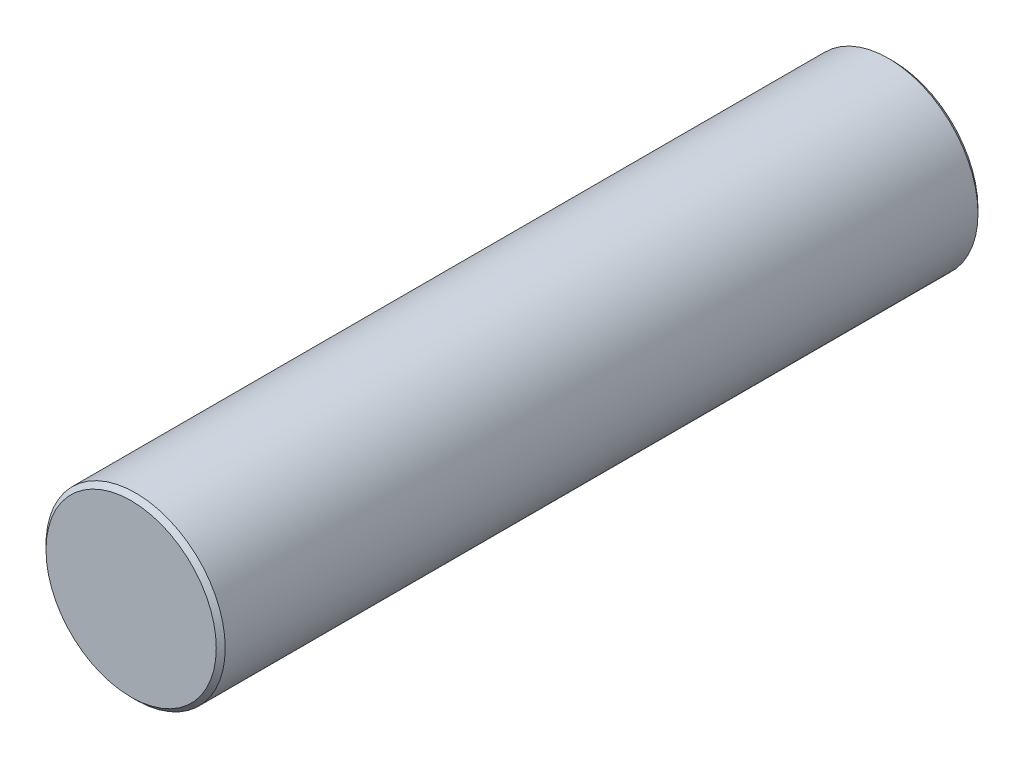
from build123d import *

# Parameters (mm, degrees)
SKETCH1_R           = 20
BOSS_EXTRUDE1_DEPTH = 170
CHAMFER1_SIZE       = 1


with BuildPart() as part:
    # Sketch1 → Boss-Extrude1 (new body)
    with BuildSketch(Plane.XY):
        Circle(SKETCH1_R)
    extrude(amount=BOSS_EXTRUDE1_DEPTH)

    # Chamfer1
    chamfer1_edges = [part.edges().sort_by_distance(p)[0] for p in [
        (-20, 0, 0),
        (-20, 0, 170),
    ]]
    chamfer(chamfer1_edges, length=CHAMFER1_SIZE)


solid = part.part
